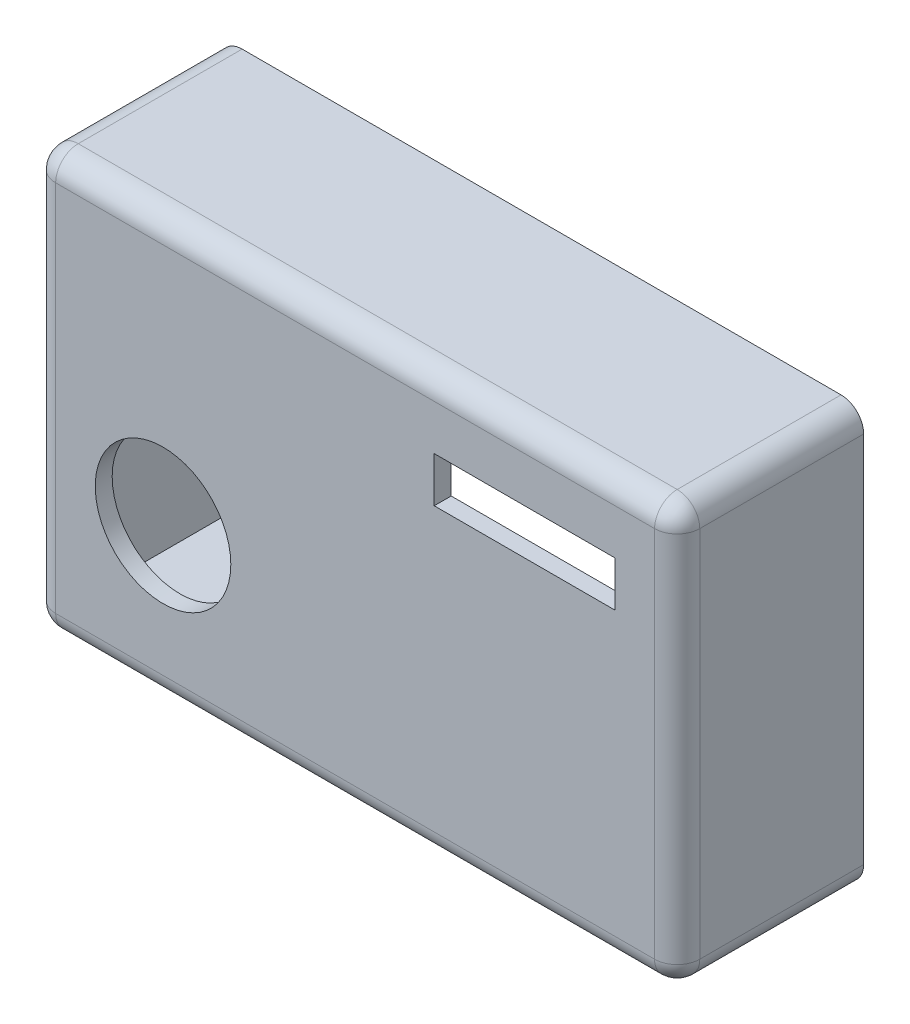
from build123d import *

# Parameters (mm, degrees)
BOSS_EXTRUDE1_DEPTH      = 1.5
SKETCH2_R                = 6
SKETCH2_W                = 16
SKETCH2_H                = 4
CUT_EXTRUDE1_DEPTH       = 2
SKETCH3_W                = 57
SKETCH3_H                = 37
SKETCH3_W_2              = 54
SKETCH3_H_2              = 34
BOSS_EXTRUDE2_DEPTH      = 15
BOSS_EXTRUDE2_DEPTH_BACK = 1.5
FILLET1_R                = 2


with BuildPart() as part:
    # Sketch1 → Boss-Extrude1 (new body)
    with BuildSketch(Plane.XY):
        Polygon((-27, -17), (-7.5, -17), (7.5, -17), (27, -17), (27, 17), (-27, 17), align=None)
    extrude(amount=BOSS_EXTRUDE1_DEPTH)

    # Sketch2 → Cut-Extrude1 (cut)
    with BuildSketch(Plane.XY.offset(1.5)):
        with Locations((-17, -5)):
            Circle(SKETCH2_R)
        with Locations((15, 10.5)):
            Rectangle(SKETCH2_W, SKETCH2_H)
    extrude(amount=-CUT_EXTRUDE1_DEPTH, mode=Mode.SUBTRACT)

    # Sketch3 → Boss-Extrude2 (add, two sides)
    with BuildSketch(Plane(origin=(0, 0, 0), x_dir=(-1, 0, 0), z_dir=(0, 0, -1))) as boss_extrude2_sk:
        Rectangle(SKETCH3_W, SKETCH3_H)
        Rectangle(SKETCH3_W_2, SKETCH3_H_2, mode=Mode.SUBTRACT)
    extrude(amount=BOSS_EXTRUDE2_DEPTH)
    extrude(boss_extrude2_sk.sketch, amount=-BOSS_EXTRUDE2_DEPTH_BACK)

    # Fillet1
    fillet1_edges = [part.edges().sort_by_distance(p)[0] for p in [
        (28.5, -18.5, -6.75),
        (28.5, 0, 1.5),
        (28.5, 18.5, -6.75),
        (0, 18.5, 1.5),
        (-28.5, 18.5, -6.75),
        (-28.5, 0, 1.5),
        (-28.5, -18.5, -6.75),
        (0, -18.5, 1.5),
    ]]
    fillet(fillet1_edges, radius=FILLET1_R)


solid = part.part
